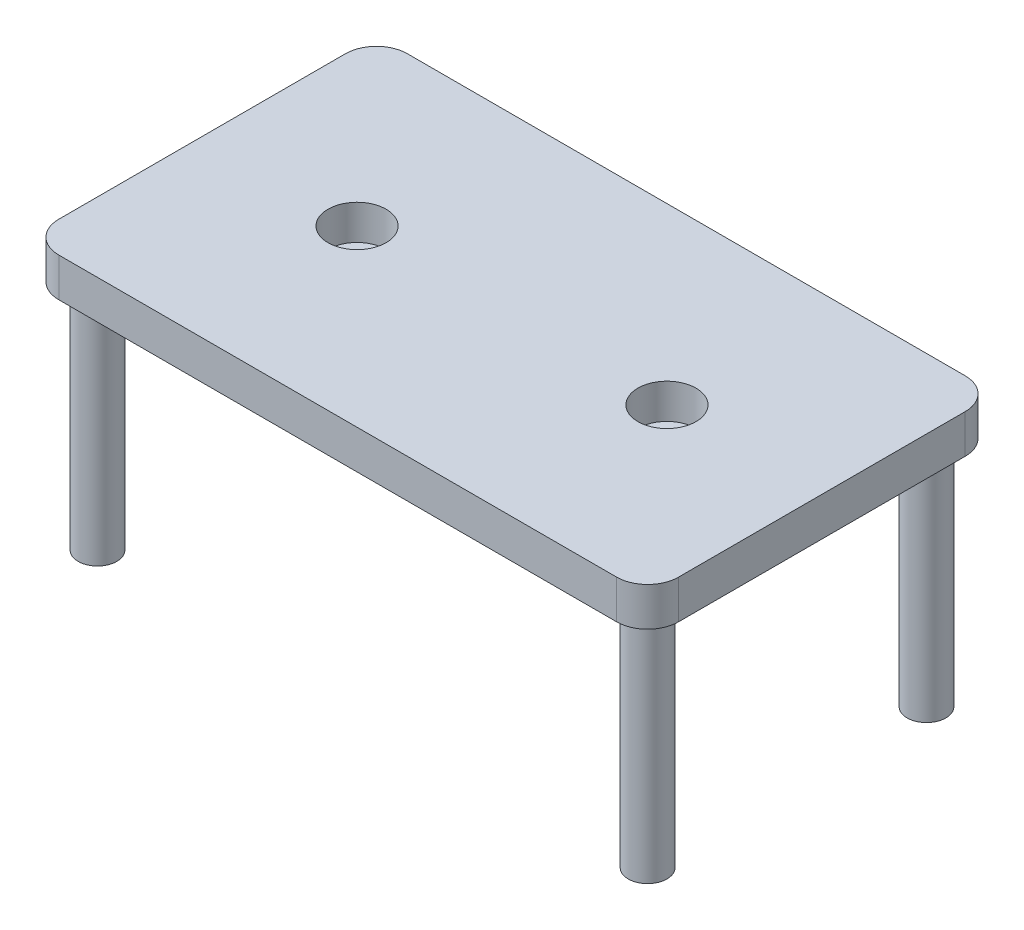
from build123d import *

# Parameters (mm, degrees)
SKETCH5_W           = 1600
SKETCH5_H           = 900
BOSS_EXTRUDE4_DEPTH = 100
SKETCH6_R           = 50
BOSS_EXTRUDE5_DEPTH = 700
SKETCH8_R           = 75
CUT_EXTRUDE2_DEPTH  = 90
FILLET2_R           = 80


with BuildPart() as part:
    # Sketch5 → Boss-Extrude4 (new body)
    with BuildSketch(Plane(origin=(0, 0, 0), x_dir=(1, 0, 0), z_dir=(0, 1, 0))):
        Rectangle(SKETCH5_W, SKETCH5_H)
    extrude(amount=BOSS_EXTRUDE4_DEPTH)

    # Sketch6 → Boss-Extrude5 (add)
    with BuildSketch(Plane(origin=(0, 100, 0), x_dir=(1, 0, 0), z_dir=(0, 1, 0))):
        with Locations((-710, 360)):
            Circle(SKETCH6_R)
        with Locations((710, 360)):
            Circle(SKETCH6_R)
        with Locations((710, -360)):
            Circle(SKETCH6_R)
        with Locations((-710, -360)):
            Circle(SKETCH6_R)
    extrude(amount=-BOSS_EXTRUDE5_DEPTH)

    # Sketch8 → Cut-Extrude2 (cut)
    with BuildSketch(Plane(origin=(0, 100, 0), x_dir=(1, 0, 0), z_dir=(0, 1, 0))):
        with Locations((400, 0)):
            Circle(SKETCH8_R)
    cut_extrude2 = extrude(amount=-CUT_EXTRUDE2_DEPTH, mode=Mode.SUBTRACT)

    # Mirror1: Cut-Extrude2 across plane
    add(cut_extrude2.mirror(Plane(origin=(0, 0, 0), x_dir=(0, 0, 1), z_dir=(1, 0, 0))), mode=Mode.SUBTRACT)

    # Fillet2
    fillet2_edges = [part.edges().sort_by_distance(p)[0] for p in [
        (800, 50, 450),
        (-800, 50, 450),
        (-800, 50, -450),
        (800, 50, -450),
    ]]
    fillet(fillet2_edges, radius=FILLET2_R)


solid = part.part
